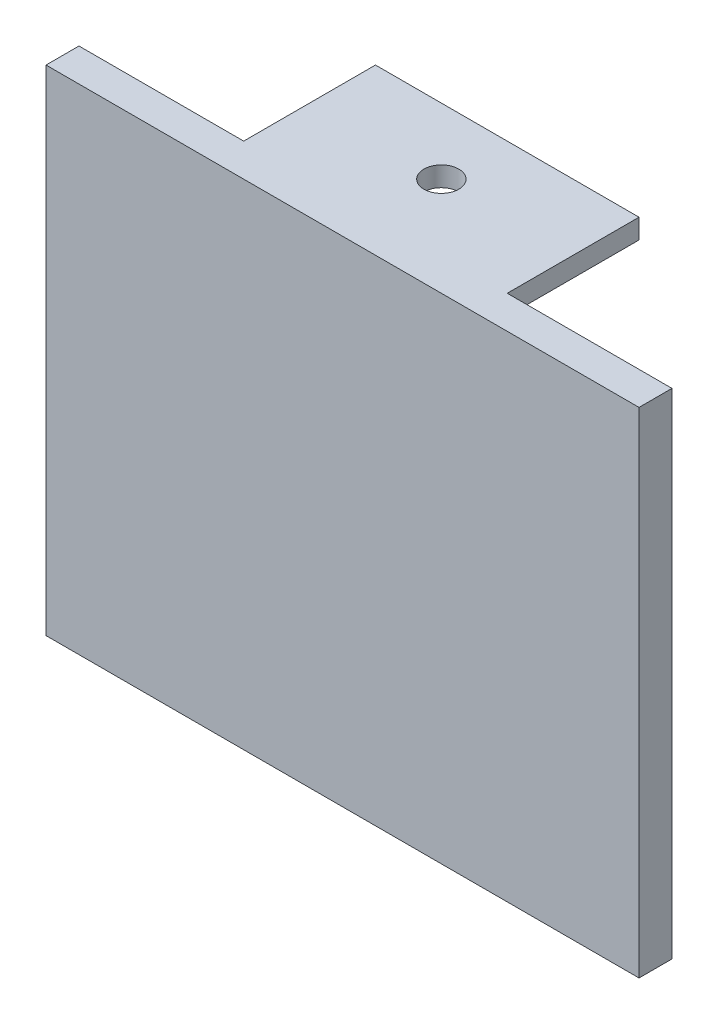
from build123d import *

# Parameters (mm, degrees)
SKETCH_1_W          = 90
SKETCH_1_H          = 75
EXTRUDE_1_DEPTH     = 5
SKETCH_3_W          = 40
SKETCH_3_H          = 3
EXTRUDE_2_DEPTH     = 20
SKETCH_4_R          = 2.65
CUT_EXTRUDE_2_DEPTH = 20
SKETCH_5_W          = 85
SKETCH_5_H          = 69
CUT_EXTRUDE_3_DEPTH = 3


with BuildPart() as part:
    # 草图1 → 凸台-拉伸1 (new body)
    with BuildSketch(Plane.XY):
        with Locations((-1.168582375, -16.58045977)):
            Rectangle(SKETCH_1_W, SKETCH_1_H)
    extrude(amount=EXTRUDE_1_DEPTH)

    # 草图3 → 凸台-拉伸2 (add)
    with BuildSketch(Plane(origin=(0, 0, 0), x_dir=(-1, 0, 0), z_dir=(0, 0, -1))):
        with Locations((1.168582375, 19.41954023)):
            Rectangle(SKETCH_3_W, SKETCH_3_H)
    extrude(amount=EXTRUDE_2_DEPTH)

    # 草图4 → 切除-拉伸2 (cut)
    with BuildSketch(Plane(origin=(0, 20.91954023, 0), x_dir=(1, 0, 0), z_dir=(0, 1, 0))):
        with Locations((-1.168582375, 10)):
            Circle(SKETCH_4_R)
    extrude(amount=-CUT_EXTRUDE_2_DEPTH, mode=Mode.SUBTRACT)

    # 草图5 → 切除-拉伸3 (cut)
    with BuildSketch(Plane(origin=(0, 0, 0), x_dir=(-1, 0, 0), z_dir=(0, 0, -1))):
        with Locations((1.475961606, -17.646255622)):
            Rectangle(SKETCH_5_W, SKETCH_5_H)
    extrude(amount=-CUT_EXTRUDE_3_DEPTH, mode=Mode.SUBTRACT)


solid = part.part
